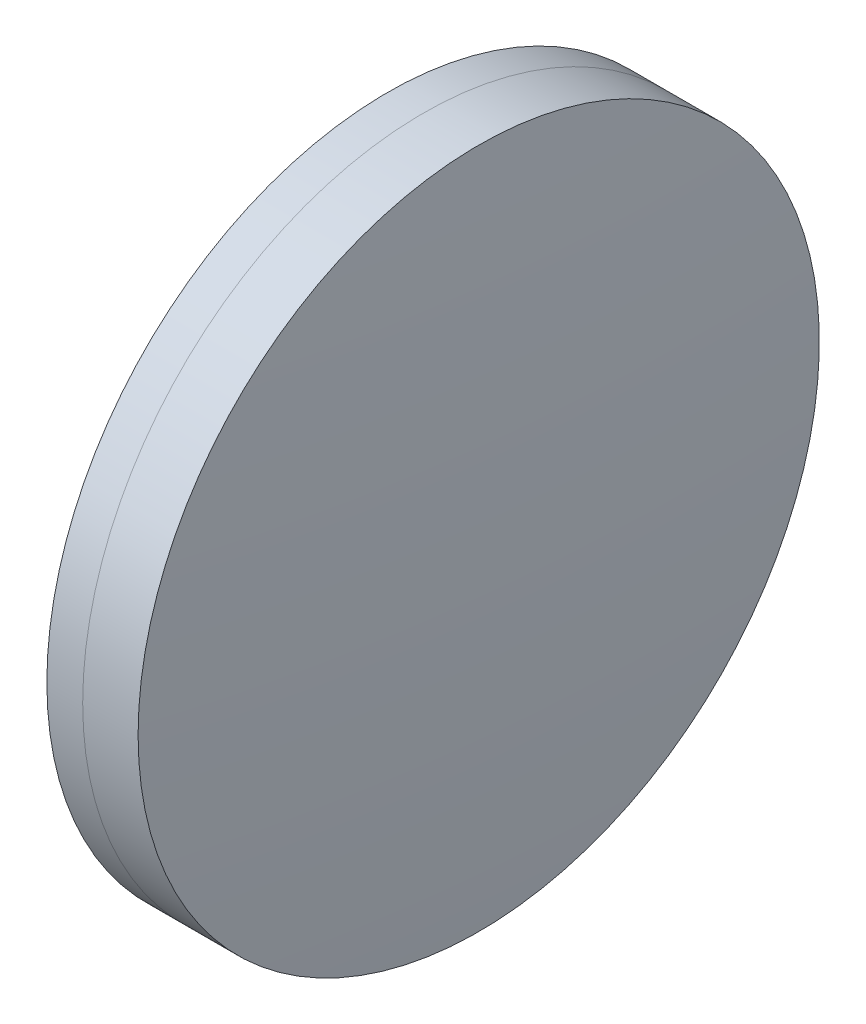
from build123d import *


with BuildPart() as part:
    # 草图1 one side → 旋转1 (revolve)
    with BuildSketch(Plane(origin=(0, 0, 0), x_dir=(1, 0, 0), z_dir=(0, 1, 0)), mode=Mode.PRIVATE) as revolve_1_sk:
        with BuildLine():
            ThreePointArc((244.880975766, 25), (243.374834193, 12.540306548), (242.871708919, 0))
            Line((242.871708919, 0), (250.181708919, 0))
            ThreePointArc((250.181708919, 0), (249.512018283, 12.57114964), (247.510526949, 25))
            Line((247.510526949, 25), (244.880975766, 25))
        make_face()
    revolve(revolve_1_sk.sketch.rotate(Axis((124.523309526, 0, 0), (1, 0, 0)), 180), axis=Axis((124.523309526, 0, 0), (1, 0, 0)))  # turned: the seam where the file's is


with BuildPart() as body_2:
    # 草图2 one side → 旋转3 (revolve)
    with BuildSketch(Plane(origin=(0, 0, 0), x_dir=(1, 0, 0), z_dir=(0, 1, 0)), mode=Mode.PRIVATE) as revolve_3_sk:
        with BuildLine():
            Line((251.577458699, 25), (247.510526949, 25))
            ThreePointArc((247.510526949, 25), (249.512018283, 12.57114964), (250.181708919, 0))
            Line((250.181708919, 0), (252.431708919, 0))
            ThreePointArc((252.431708919, 0), (252.218084062, 12.507295306), (251.577458699, 25))
        make_face()
    revolve(revolve_3_sk.sketch.rotate(Axis((-0.551919993, 0, 0), (1, 0, 0)), 180), axis=Axis((-0.551919993, 0, 0), (1, 0, 0)))  # turned: the seam where the file's is


solid = Compound([part.part, body_2.part])
